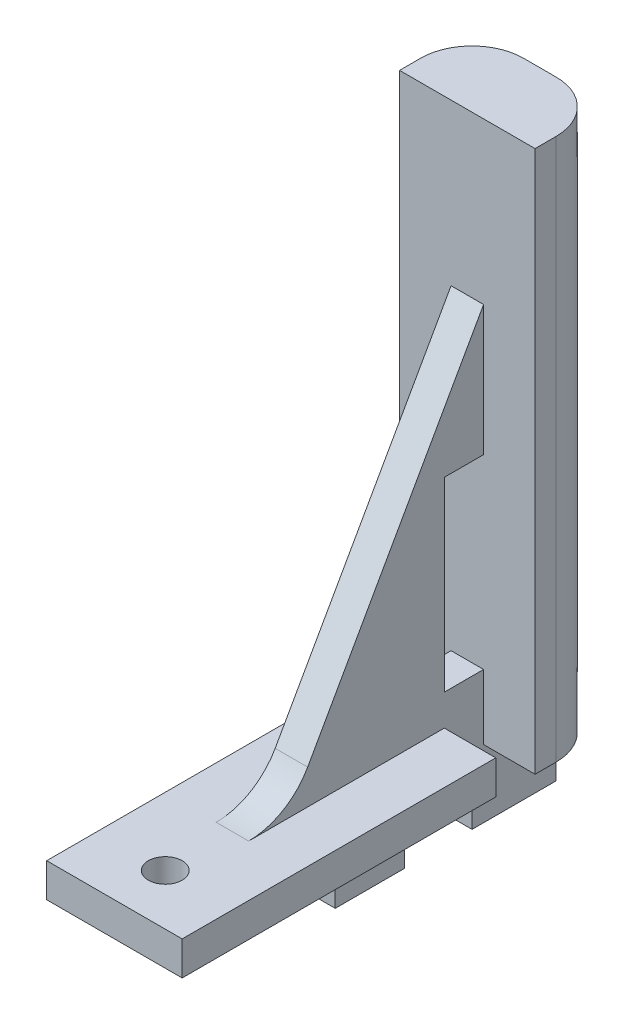
from build123d import *

# Parameters (mm, degrees)
BOSS_EXTRUDE1_DEPTH     = 6.35
SKETCH1_4_W             = 3.683
SKETCH1_4_H             = 17.441333418
CUT_EXTRUDE2_DEPTH      = 7.35
CUT_EXTRUDE2_DEPTH_BACK = 7.35
SKETCH1_3_W             = 6.477
SKETCH1_3_H             = 6.35
BOSS_EXTRUDE2_DEPTH     = 1.524
SKETCH2_R               = 1.5875
CUT_EXTRUDE1_DEPTH      = 51.8
FILLET1_R               = 4.826
FILLET2_R               = 6.35
SKETCH3_W               = 1.27
SKETCH3_H               = 9.525
CUT_EXTRUDE3_DEPTH      = 7.35
CUT_EXTRUDE3_DEPTH_BACK = 7.35
SKETCH4_W               = 4.826
SKETCH4_H               = 33.0835
CUT_EXTRUDE5_DEPTH      = 47.625
SKETCH5_W               = 3.683
SKETCH5_H               = 6.096
CUT_EXTRUDE6_DEPTH      = 4.826
CUT_EXTRUDE7_START      = -12.7
SKETCH5_2_W             = 3.683
SKETCH5_2_H             = 6.096
CUT_EXTRUDE7_DEPTH      = 4.826


with BuildPart() as part:
    # Sketch1 → Boss-Extrude1 (new body, symmetric)
    with BuildSketch(Plane(origin=(0, 0, 0), x_dir=(0, 0, -1), z_dir=(1, 0, 0))):
        Polygon((-19.939, 3.175), (-19.939, 0), (19.939, 0), (19.939, 50.8), (13.1445, 50.8), (13.1445, 35.729333418), (-5.167312548, 3.175), align=None)
    extrude(amount=BOSS_EXTRUDE1_DEPTH, both=True)

    # Sketch1_4 → Cut-Extrude2 (cut, two sides)
    with BuildSketch(Plane(origin=(0, 0, 0), x_dir=(0, 0, -1), z_dir=(1, 0, 0))) as cut_extrude2_sk:
        with Locations((11.303, 14.816666709)):
            Rectangle(SKETCH1_4_W, SKETCH1_4_H)
    extrude(amount=CUT_EXTRUDE2_DEPTH, mode=Mode.SUBTRACT)
    extrude(cut_extrude2_sk.sketch, amount=-CUT_EXTRUDE2_DEPTH_BACK, mode=Mode.SUBTRACT)

    # Sketch1_3 → Boss-Extrude2 (add, symmetric)
    with BuildSketch(Plane(origin=(0, 0, 0), x_dir=(0, 0, -1), z_dir=(1, 0, 0))):
        Polygon((13.1445, 0), (12.065, 0), (12.065, -6.35), (19.939, -6.35), (19.939, 0), align=None)
        with Locations((2.4765, -3.175)):
            Rectangle(SKETCH1_3_W, SKETCH1_3_H)
    extrude(amount=BOSS_EXTRUDE2_DEPTH, both=True)

    # Sketch2 → Cut-Extrude1 (cut, through all)
    with BuildSketch(Plane.XZ):
        with Locations((0, 15.1765)):
            Circle(SKETCH2_R)
    extrude(amount=-CUT_EXTRUDE1_DEPTH, mode=Mode.SUBTRACT)

    # Fillet1
    fillet1_edges = [part.edges().sort_by_distance(p)[0] for p in [
        (-6.35, 25.4, -19.939),
        (6.35, 25.4, -19.939),
    ]]
    fillet(fillet1_edges, radius=FILLET1_R)

    # Fillet2
    fillet2_edges = [part.edges().sort_by_distance(p)[0] for p in [
        (0, 3.175, 5.167312548),
    ]]
    fillet(fillet2_edges, radius=FILLET2_R)

    # Sketch3 → Cut-Extrude3 (cut, two sides)
    with BuildSketch(Plane(origin=(0, 0, 0), x_dir=(0, 0, -1), z_dir=(1, 0, 0))) as cut_extrude3_sk:
        with Locations((19.304, 33.3375)):
            Rectangle(SKETCH3_W, SKETCH3_H)
    extrude(amount=CUT_EXTRUDE3_DEPTH, mode=Mode.SUBTRACT)
    extrude(cut_extrude3_sk.sketch, amount=-CUT_EXTRUDE3_DEPTH_BACK, mode=Mode.SUBTRACT)

    # Sketch4 → Cut-Extrude5 (cut)
    with BuildSketch(Plane(origin=(0, 50.8, 0), x_dir=(1, 0, 0), z_dir=(0, 1, 0))):
        with Locations((-3.937, -3.39725)):
            Rectangle(SKETCH4_W, SKETCH4_H)
        with Locations((3.937, -3.39725)):
            Rectangle(SKETCH4_W, SKETCH4_H)
    extrude(amount=-CUT_EXTRUDE5_DEPTH, mode=Mode.SUBTRACT)

    # Sketch5 → Cut-Extrude6 (cut)
    with BuildSketch(Plane(origin=(6.35, 0, 0), x_dir=(0, 0, -1), z_dir=(1, 0, 0))):
        with Locations((11.303, 3.048)):
            Rectangle(SKETCH5_W, SKETCH5_H)
    extrude(amount=-CUT_EXTRUDE6_DEPTH, mode=Mode.SUBTRACT)

    # Sketch5_2 → Cut-Extrude7 (cut)
    with BuildSketch(Plane(origin=(6.35, 0, 0), x_dir=(0, 0, -1), z_dir=(1, 0, 0)).offset(CUT_EXTRUDE7_START)):
        with Locations((11.303, 3.048)):
            Rectangle(SKETCH5_2_W, SKETCH5_2_H)
    extrude(amount=CUT_EXTRUDE7_DEPTH, mode=Mode.SUBTRACT)


solid = part.part
